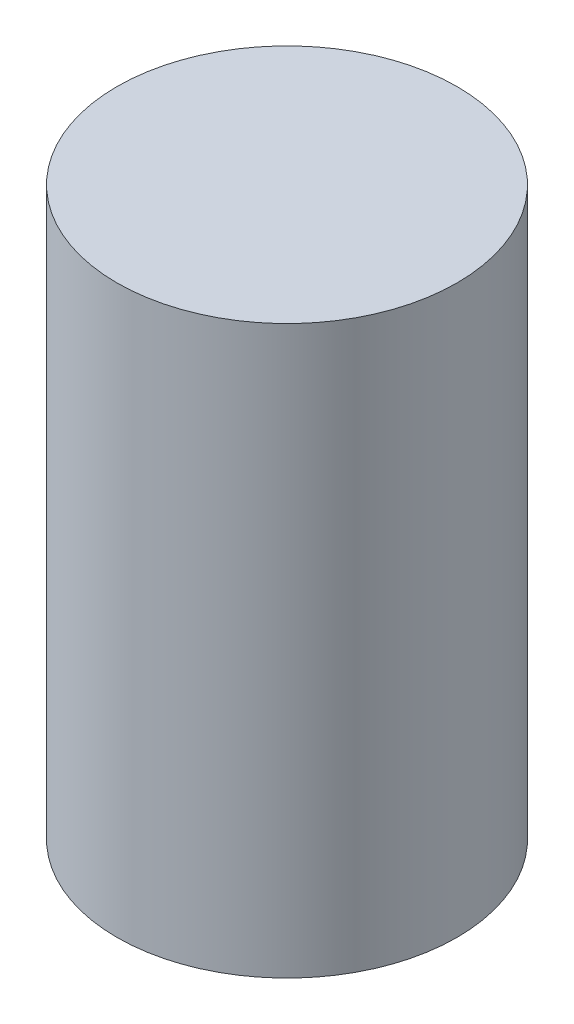
from build123d import *

# Parameters (mm, degrees)
CROQUIS1_R              = 3.81
SALIENTE_EXTRUIR1_DEPTH = 12.7


with BuildPart() as part:
    # Croquis1 → Saliente-Extruir1 (new body)
    with BuildSketch(Plane(origin=(0, 0, 0), x_dir=(1, 0, 0), z_dir=(0, 1, 0))):
        Circle(CROQUIS1_R)
    extrude(amount=SALIENTE_EXTRUIR1_DEPTH)


solid = part.part
